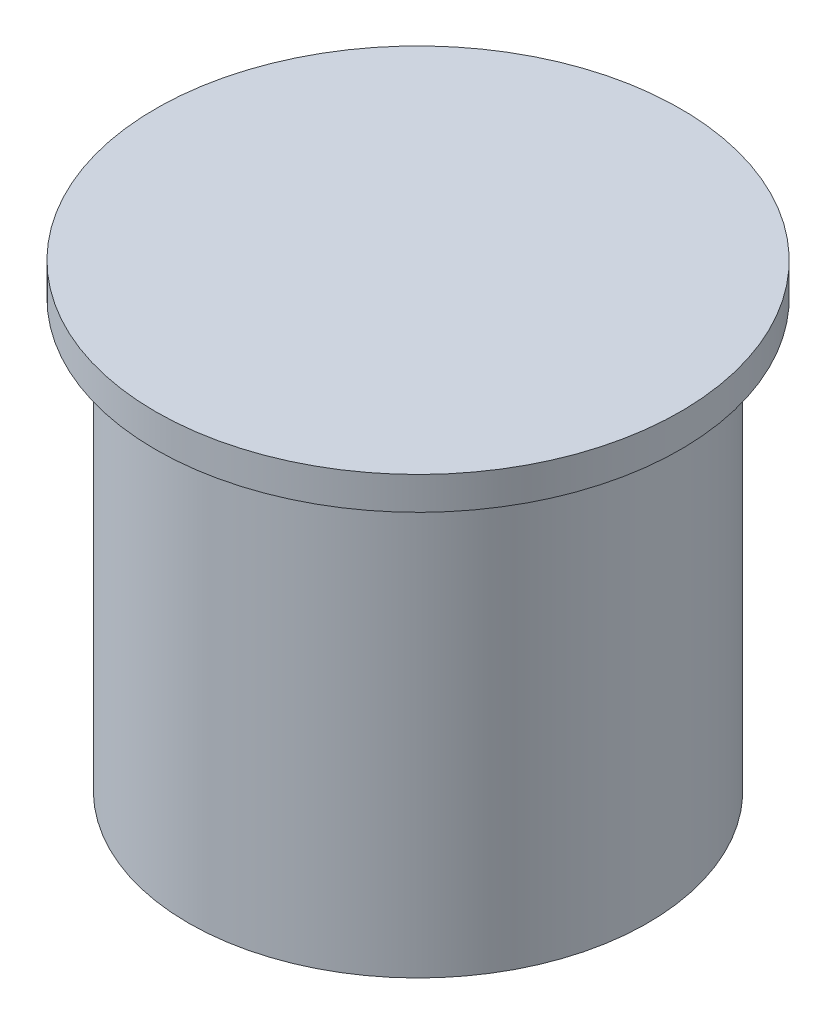
from build123d import *


with BuildPart() as part:
    # 草圖1 → 旋轉1 (revolve)
    with BuildSketch(Plane.XY):
        Polygon((0, 14), (8, 14), (8, 13), (7, 13), (7, 0), (0, 0), align=None)
    revolve(axis=Axis((0, 18.011449723, 0), (0, -1, 0)))


solid = part.part
